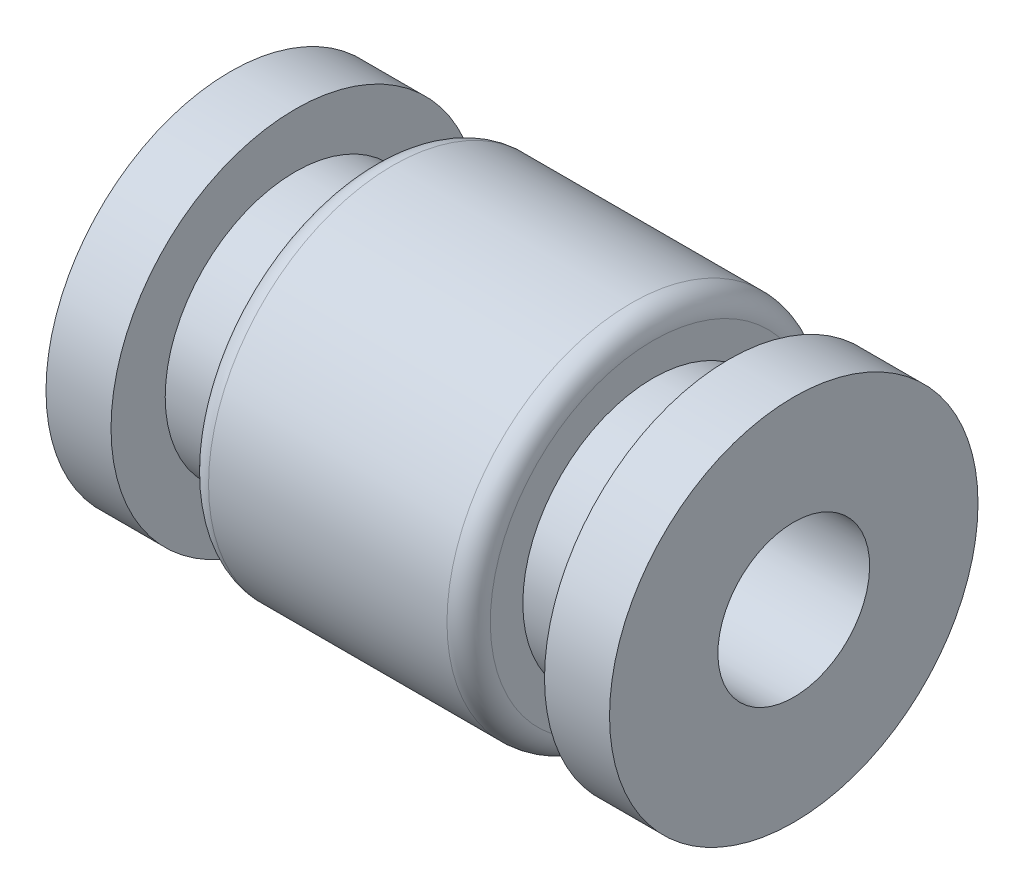
from build123d import *

# Parameters (mm, degrees)
SKETCH2_R          = 1.75
CUT_EXTRUDE1_DEPTH = 14
FILLET1_R          = 0.5


with BuildPart() as part:
    # Sketch1 → Revolve1 (revolve)
    with BuildSketch(Plane.XY):
        Polygon((-6.5, 0), (-6.5, 4.25), (-5, 4.25), (-5, 3), (-3.25, 3), (-3.25, 4.25), (3.25, 4.25), (3.25, 3), (5, 3), (5, 4.25), (6.5, 4.25), (6.5, 0), align=None)
    revolve(axis=Axis((6.5, 0, 0), (-1, 0, 0)))

    # Sketch2 → Cut-Extrude1 (cut, through all)
    with BuildSketch(Plane(origin=(6.5, 0, 0), x_dir=(0, 0, -1), z_dir=(1, 0, 0))):
        Circle(SKETCH2_R)
    extrude(amount=-CUT_EXTRUDE1_DEPTH, mode=Mode.SUBTRACT)

    # Fillet1
    fillet1_edges = [part.edges().sort_by_distance(p)[0] for p in [
        (3.25, -4.25, 0),
        (-3.25, -4.25, 0),
    ]]
    fillet(fillet1_edges, radius=FILLET1_R)


solid = part.part
